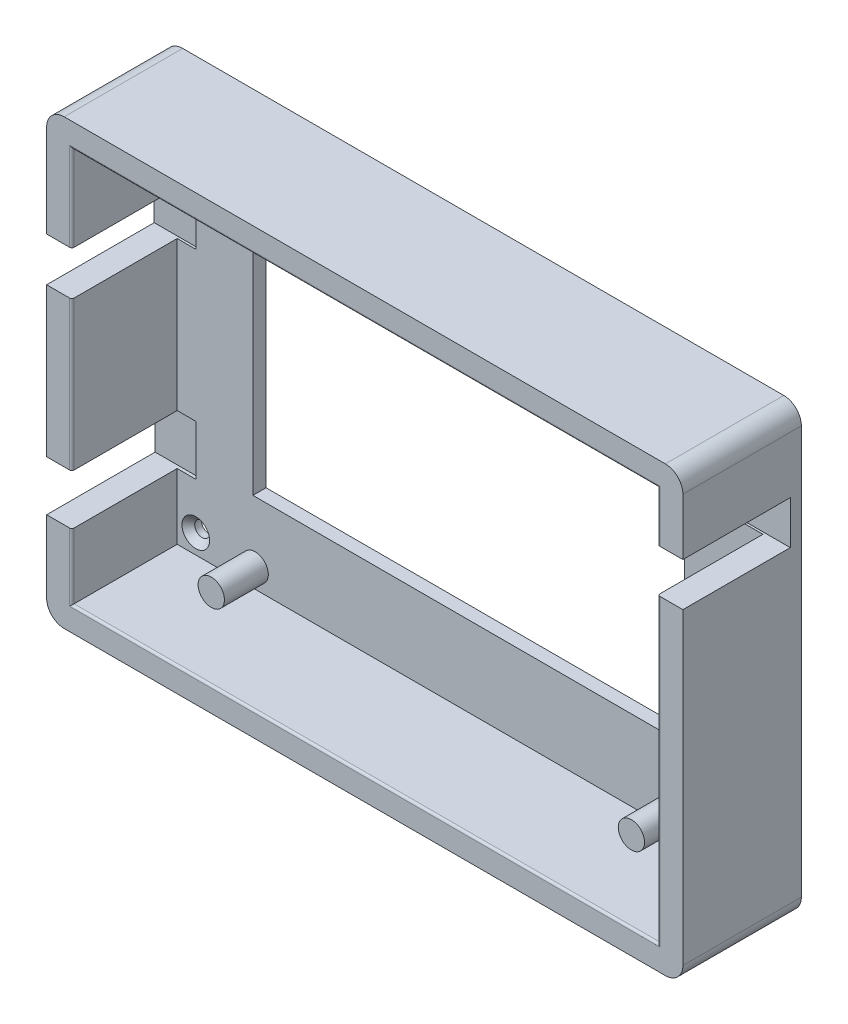
from build123d import *

# Parameters (mm, degrees)
BOSS_EXTRU_1_DEPTH                             = 19
BOSS_EXTRU_1_DEPTH_BACK                        = 8
ESQUISSE1_W                                    = 133.5
ESQUISSE1_H                                    = 90
ENL_V_MAT_EXTRU_1_DEPTH                        = 47
ENL_V_MAT_EXTRU_1_DEPTH_BACK                   = 5
FRAISAGE_POUR_VIS_T_TE_FRAIS_E_M32_D           = 3.4
FRAISAGE_POUR_VIS_T_TE_FRAIS_E_M32_DEPTH       = 5
FRAISAGE_POUR_VIS_T_TE_FRAIS_E_M32_CSINK_D     = 6.3
FRAISAGE_POUR_VIS_T_TE_FRAIS_E_M32_CSINK_ANGLE = 90
FRAISAGE_POUR_VIS_T_TE_FRAIS_E_M32_TIP         = 1.021463052
ESQUISSE7_W                                    = 24.511286956
ESQUISSE7_H                                    = 10.008551301
ENL_V_MAT_EXTRU_2_DEPTH                        = 10
ESQUISSE8_W                                    = 24.723742657
ESQUISSE8_H                                    = 11.436875975
ENL_V_MAT_EXTRU_3_DEPTH                        = 10
ESQUISSE9_W                                    = 24.478686325
ESQUISSE9_H                                    = 9.877285249
ENL_V_MAT_EXTRU_4_DEPTH                        = 10
CONG_1_R                                       = 0.5
ESQUISSE10_R                                   = 3
BOSS_EXTRU_2_DEPTH                             = 10
ESQUISSE12_W                                   = 98.408714422
ESQUISSE12_H                                   = 55.172933086
ENL_V_MAT_EXTRU_5_DEPTH                        = 10


with BuildPart() as part:
    # EsquisseExterieur → Boss.-Extru.1 (new body, two sides)
    with BuildSketch(Plane.XY) as boss_extru_1_sk:
        with BuildLine():
            Line((-1.75, -5.5), (135.25, -5.5))
            ThreePointArc((135.25, -5.5), (138.078427125, -4.328427125), (139.25, -1.5))
            Line((139.25, -1.5), (139.25, 91.5))
            ThreePointArc((139.25, 91.5), (138.078427125, 94.328427125), (135.25, 95.5))
            Line((135.25, 95.5), (-1.75, 95.5))
            ThreePointArc((-1.75, 95.5), (-4.578427125, 94.328427125), (-5.75, 91.5))
            Line((-5.75, 91.5), (-5.75, -1.5))
            ThreePointArc((-5.75, -1.5), (-4.578427125, -4.328427125), (-1.75, -5.5))
        make_face()
    extrude(amount=BOSS_EXTRU_1_DEPTH)
    extrude(boss_extru_1_sk.sketch, amount=-BOSS_EXTRU_1_DEPTH_BACK)

    # Esquisse1 → Enlèv. mat.-Extru.1 (cut, two sides)
    with BuildSketch(Plane.XY) as enl_v_mat_extru_1_sk:
        with Locations((66.75, 45)):
            Rectangle(ESQUISSE1_W, ESQUISSE1_H)
    extrude(amount=ENL_V_MAT_EXTRU_1_DEPTH, mode=Mode.SUBTRACT)
    extrude(enl_v_mat_extru_1_sk.sketch, amount=-ENL_V_MAT_EXTRU_1_DEPTH_BACK, mode=Mode.SUBTRACT)

    # Fraisage pour vis à tête fraisée M32
    with Locations(Plane.XY.offset(-5)):
        with Locations((4.145138972, 84.443401206), (127.127377422, 84.443401206), (127.127377422, 4.415852319), (4.240996888, 4.415852319)):
            CounterSinkHole(FRAISAGE_POUR_VIS_T_TE_FRAIS_E_M32_D / 2, FRAISAGE_POUR_VIS_T_TE_FRAIS_E_M32_CSINK_D / 2, depth=FRAISAGE_POUR_VIS_T_TE_FRAIS_E_M32_DEPTH, counter_sink_angle=FRAISAGE_POUR_VIS_T_TE_FRAIS_E_M32_CSINK_ANGLE)
            with Locations((0, 0, -(FRAISAGE_POUR_VIS_T_TE_FRAIS_E_M32_DEPTH + FRAISAGE_POUR_VIS_T_TE_FRAIS_E_M32_TIP / 2))):  # 118° drill point
                Cone(0, FRAISAGE_POUR_VIS_T_TE_FRAIS_E_M32_D / 2, FRAISAGE_POUR_VIS_T_TE_FRAIS_E_M32_TIP, mode=Mode.SUBTRACT)

    # Esquisse7 → Enlèv. mat.-Extru.2 (cut)
    with BuildSketch(Plane.ZY.offset(5.75)):
        with Locations((6.744356522, 65.353288209)):
            Rectangle(ESQUISSE7_W, ESQUISSE7_H)
    extrude(amount=-ENL_V_MAT_EXTRU_2_DEPTH, mode=Mode.SUBTRACT)

    # Esquisse8 → Enlèv. mat.-Extru.3 (cut)
    with BuildSketch(Plane.ZY.offset(5.75)):
        with Locations((6.638128671, 20.678831333)):
            Rectangle(ESQUISSE8_W, ESQUISSE8_H)
    extrude(amount=-ENL_V_MAT_EXTRU_3_DEPTH, mode=Mode.SUBTRACT)

    # Esquisse9 → Enlèv. mat.-Extru.4 (cut)
    with BuildSketch(Plane(origin=(139.25, 0, 0), x_dir=(0, 0, -1), z_dir=(1, 0, 0))):
        with Locations((-6.760656838, 73.668720261)):
            Rectangle(ESQUISSE9_W, ESQUISSE9_H)
    extrude(amount=-ENL_V_MAT_EXTRU_4_DEPTH, mode=Mode.SUBTRACT)

    # Congé1
    cong_1_edges = [part.edges().sort_by_distance(p)[0] for p in [
        (0, 7.480196672, 19),
        (133.5, 84.303681443, 19),
        (66.75, 90, 19),
        (133.5, 34.365038818, 19),
        (66.75, 0, 19),
        (0, 80.17878193, 19),
        (0, 43.373140939, 19),
    ]]
    fillet(cong_1_edges, radius=CONG_1_R)

    # Esquisse10 → Boss.-Extru.2 (add)
    with BuildSketch(Plane.XY.offset(-5)):
        with Locations((17.770805857, 84.443401206)):
            Circle(ESQUISSE10_R)
        with Locations((113.513450355, 84.443401206)):
            Circle(ESQUISSE10_R)
        with Locations((17.770805857, 4.415852319)):
            Circle(ESQUISSE10_R)
        with Locations((113.513450355, 4.415852319)):
            Circle(ESQUISSE10_R)
    extrude(amount=BOSS_EXTRU_2_DEPTH)

    # Esquisse12 → Enlèv. mat.-Extru.5 (cut)
    with BuildSketch(Plane.XY.offset(-5)):
        with Locations((66.458849957, 45.873450128)):
            Rectangle(ESQUISSE12_W, ESQUISSE12_H)
    extrude(amount=-ENL_V_MAT_EXTRU_5_DEPTH, mode=Mode.SUBTRACT)


solid = part.part
